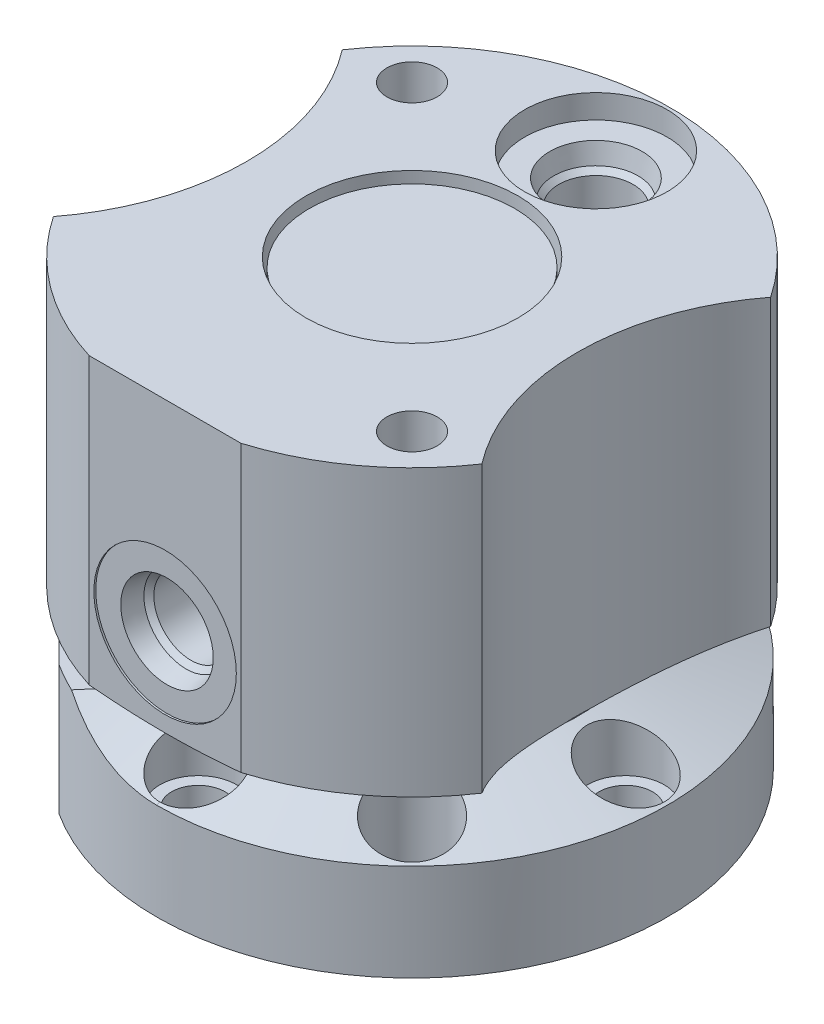
from build123d import *

# Parameters (mm, degrees)
SKETCH1_R                = 34.163
EXTRUDE1_DEPTH           = 17.2974
CUT_REVOLVE11_ANGLE      = 270
SKETCH31_R               = 38.1
CUT_EXTRUDE18_DEPTH      = 53.987387501
CUT_EXTRUDE18_DEPTH_BACK = 18.134109734
SKETCH32_R               = 38.1
CUT_EXTRUDE19_DEPTH      = 53.987387629
CUT_EXTRUDE19_DEPTH_BACK = 18.134109862
CUT_EXTRUDE14_REACH      = 19.297
HOLE1_D                  = 7.1374
HOLE1_DEPTH              = 17.2984
HOLE1_CBORE_D            = 10.3124
HOLE1_CBORE_DEPTH        = 7.366
CIRPATTERN1_COUNT        = 4
HOLE2_D                  = 10.3124
HOLE2_DEPTH              = 17.2984
CIRPATTERN2_COUNT        = 2
CUT_EXTRUDE15_REACH      = 61.36
CUT_EXTRUDE20_START      = -59.3598
SKETCH37_R               = 31.75
CUT_EXTRUDE20_DEPTH      = 59.3598
CIRPATTERN3_COUNT        = 2
SKETCH42_W               = 2.7686
SKETCH42_H               = 17.2974


with BuildPart() as part:
    # Sketch1 → Extrude1 (new body)
    with BuildSketch(Plane(origin=(0, 0, 0), x_dir=(1, 0, 0), z_dir=(0, 1, 0))):
        with Locations(Location((0, 0, 0), (0, 0, 270))):  # turned: the seam where the file's is
            Circle(SKETCH1_R)
    extrude(amount=-EXTRUDE1_DEPTH)

    # Sketch30 → Cut-Revolve11 (revolve, cut)
    with BuildSketch(Plane(origin=(0, 0, 0), x_dir=(0, 0, -1), z_dir=(1, 0, 0))):
        Polygon((-22.225, 0), (-34.163, 0), (-34.163, -4.345076657), align=None)
    revolve(axis=Axis((0, 0, 0), (0, 1, 0)), revolution_arc=CUT_REVOLVE11_ANGLE, mode=Mode.SUBTRACT)

    # Sketch31 → Cut-Extrude18 (cut, two sides)
    with BuildSketch(Plane(origin=(-22.225, 0, 0), x_dir=(0, 0, -1), z_dir=(0.939692621, 0.342020143, 0))) as cut_extrude18_sk:
        with Locations((0, 38.1)):
            Circle(SKETCH31_R)
    extrude(amount=CUT_EXTRUDE18_DEPTH, mode=Mode.SUBTRACT)
    extrude(cut_extrude18_sk.sketch, amount=-CUT_EXTRUDE18_DEPTH_BACK, mode=Mode.SUBTRACT)

    # Sketch32 → Cut-Extrude19 (cut, two sides)
    with BuildSketch(Plane(origin=(0, 0, 22.225), x_dir=(-1, 0, 0), z_dir=(0, 0.342020143, -0.939692621))) as cut_extrude19_sk:
        with Locations((0, 38.1)):
            Circle(SKETCH32_R)
    extrude(amount=CUT_EXTRUDE19_DEPTH, mode=Mode.SUBTRACT)
    extrude(cut_extrude19_sk.sketch, amount=-CUT_EXTRUDE19_DEPTH_BACK, mode=Mode.SUBTRACT)

    # Sketch20 → Cut-Extrude14 (cut, up to next)
    with BuildSketch(Plane.XZ.offset(17.2974), mode=Mode.PRIVATE) as cut_extrude14_sk1:
        with BuildLine():
            Line((-28.691719625, 18.544427572), (-18.544427572, 28.691719625))
            ThreePointArc((-18.544427572, 28.691719625), (-24.156888966, 24.156888966), (-28.691719625, 18.544427572))
        make_face()
    cut_extrude14_tool1 = extrude(cut_extrude14_sk1.sketch, amount=-CUT_EXTRUDE14_REACH, mode=Mode.PRIVATE) & part.part
    add(cut_extrude14_tool1.solids().sort_by_distance((-23.833807, -17.2974, 23.833807))[0], mode=Mode.SUBTRACT)

    # Sketch22 → Cut-Revolve12 (revolve, cut)
    with BuildSketch(Plane.XY):
        Polygon((-4.5466, -15.2654), (-6.35, -15.2654), (-6.35, -17.2974), (0, -17.2974), (0, -3.0734), (-3.4544, -3.0734), (-3.4544, -12.543113338), (-4.106586662, -13.1953), align=None)
    revolve(axis=Axis((0, 12.8016, 0), (0, -1, 0)), mode=Mode.SUBTRACT)

    # S2D0002 → Cut-Revolve13 (revolve, cut)
    with BuildSketch(Plane.XZ.offset(7.7724), mode=Mode.PRIVATE) as cut_revolve13_sk:
        Polygon((-23.618073598, 23.618073598), (-19.244688867, 27.991458329), (-17.823328672, 25.802755564), (-17.823328672, 24.863849471), (-10.219531466, 17.260052265), (-13.739791865, 13.739791865), align=None)
    revolve(cut_revolve13_sk.sketch.rotate(Axis((10.372221734, -7.7724, -10.372221734), (-0.707106781, 0, 0.707106781)), 180), axis=Axis((10.372221734, -7.7724, -10.372221734), (-0.707106781, 0, 0.707106781)), mode=Mode.SUBTRACT)  # turned: the seam where the file's is

    # Hole1
    with Locations(Plane(origin=(0, 0, 0), x_dir=(-1, 0, 0), z_dir=(0, 1, 0))):
        with Locations((0, -28.575)):
            hole1 = CounterBoreHole(HOLE1_D / 2, HOLE1_CBORE_D / 2, HOLE1_CBORE_DEPTH, depth=HOLE1_DEPTH)

    # CirPattern1: Hole1 ×4 about axis
    cirpattern1_axis = Axis((0, 0, 0), (0, 1, 0))
    for i in range(1, CIRPATTERN1_COUNT):
        add(hole1.rotate(cirpattern1_axis, i * 360 / CIRPATTERN1_COUNT), mode=Mode.SUBTRACT)

    # Hole2
    with Locations(Plane(origin=(0, 0, 0), x_dir=(-1, 0, 0), z_dir=(0, 1, 0))):
        with Locations((20.205576272, -20.205576272)):
            hole2 = Hole(HOLE2_D / 2, depth=HOLE2_DEPTH)

    # CirPattern2: Hole2 ×2 about axis
    cirpattern2_axis = Axis((0, 0, 0), (0, 1, 0))
    for i in range(1, CIRPATTERN2_COUNT):
        add(hole2.rotate(cirpattern2_axis, i * 360 / CIRPATTERN2_COUNT), mode=Mode.SUBTRACT)

    # Sketch42 → #97 (0.0059) Diameter Hole2 (revolve, cut)
    with BuildSketch(Plane(origin=(-19.05, -17.2974, 0), x_dir=(0, 0, -1), z_dir=(1, 0, 0))):
        with Locations((1.3843, 8.6487)):
            Rectangle(SKETCH42_W, SKETCH42_H)
    revolve(axis=Axis((-19.05, -23.6474, 0), (0, 1, 0)), mode=Mode.SUBTRACT)


with BuildPart() as body_2:
    # Sketch23 → Revolve1 (revolve)
    with BuildSketch(Plane.XY, mode=Mode.PRIVATE) as revolve1_sk:
        Polygon((14.1605, 42.0624), (34.544, 42.0624), (34.544, 3.937), (22.225, 0), (0, 0), (0, 40.8178), (13.716, 40.8178), (13.716, 34.4678), (14.1605, 34.4678), align=None)
    revolve(revolve1_sk.sketch.rotate(Axis((0, -2.10312, 0), (0, 1, 0)), 90), axis=Axis((0, -2.10312, 0), (0, 1, 0)))  # turned: the seam where the file's is

    # Cut-Extrude15: up to this cone (the profile starts inside it)
    cut_extrude15_end = Plane(origin=(0, 42.0624, 0), z_dir=(0, 1, 0)).offset(-49.165234052) * Cone(3.129e-06, 828.770633091, 264.864840503, align=(Align.CENTER, Align.CENTER, Align.MIN), mode=Mode.PRIVATE)
    # Sketch24 → Cut-Extrude15 (cut, up to the surface)
    with BuildSketch(Plane(origin=(0, 42.0624, 0), x_dir=(-1, 0, 0), z_dir=(0, 1, 0)), mode=Mode.PRIVATE) as cut_extrude15_sk1:
        with BuildLine():
            Line((10.147292053, 33.02), (-10.147292053, 33.02))
            ThreePointArc((-10.147292053, 33.02), (0, 34.544), (10.147292053, 33.02))
        make_face()
    cut_extrude15_tool1 = extrude(cut_extrude15_sk1.sketch, amount=-CUT_EXTRUDE15_REACH, mode=Mode.PRIVATE) & cut_extrude15_end
    add(cut_extrude15_tool1.solids().sort_by_distance((0, 42.0624, 33.630767))[0], mode=Mode.SUBTRACT)

    # Sketch37 → Cut-Extrude20 (cut)
    with BuildSketch(Plane(origin=(0, 42.0624, 0), x_dir=(1, 0, 0), z_dir=(0, 1, 0)).offset(CUT_EXTRUDE20_START)):
        with Locations((53.848, 0)):
            Circle(SKETCH37_R)
        with Locations((-53.848, 0)):
            Circle(SKETCH37_R)
    extrude(amount=CUT_EXTRUDE20_DEPTH, mode=Mode.SUBTRACT)

    # Sketch27 → Cut-Revolve8 (revolve, cut)
    with BuildSketch(Plane.ZY, mode=Mode.PRIVATE) as cut_revolve8_sk:
        Polygon((15.804675494, 15.0876), (18.796, 10.1092), (29.549393135, 10.1092), (30.2133, 9.445293135), (32.766, 8.9027), (32.766, 5.5626), (33.02, 5.5626), (33.02, 15.0876), align=None)
    revolve(cut_revolve8_sk.sketch.rotate(Axis((0, 15.0876, 42.869284746), (0, 0, -1)), 270), axis=Axis((0, 15.0876, 42.869284746), (0, 0, -1)), mode=Mode.SUBTRACT)  # turned: the seam where the file's is

    # Sketch28 → Cut-Revolve9 (revolve, cut)
    with BuildSketch(Plane.ZY, mode=Mode.PRIVATE) as cut_revolve9_sk:
        Polygon((-34.1122, 42.0624), (-34.1122, 38.8874), (-30.7721, 38.8874), (-30.229506865, 36.3347), (-29.5656, 35.670793135), (-29.5656, 24.9174), (-24.5872, 21.926075494), (-24.5872, 42.0624), align=None)
    revolve(cut_revolve9_sk.sketch.rotate(Axis((0, 40.243283738, -24.5872), (0, -1, 0)), 180), axis=Axis((0, 40.243283738, -24.5872), (0, -1, 0)), mode=Mode.SUBTRACT)  # turned: the seam where the file's is

    # Sketch38 → Hole3 (revolve, cut)
    with BuildSketch(Plane(origin=(20.205576272, 0, 20.205576272), x_dir=(0, 0, -1), z_dir=(1, 0, 0))):
        Polygon((0, 0), (0, 42.0624), (3.3655, 42.0624), (3.3655, 7.366), (5.207, 7.366), (5.207, 0), align=None)
    hole3 = revolve(axis=Axis((20.205576272, 110, 20.205576272), (0, -1, 0)), mode=Mode.SUBTRACT)

    # CirPattern3: Hole3 ×2 about axis
    cirpattern3_axis = Axis((0, 0, 0), (0, 1, 0))
    for i in range(1, CIRPATTERN3_COUNT):
        add(hole3.rotate(cirpattern3_axis, i * 360 / CIRPATTERN3_COUNT), mode=Mode.SUBTRACT)


solid = Compound([part.part, body_2.part])
